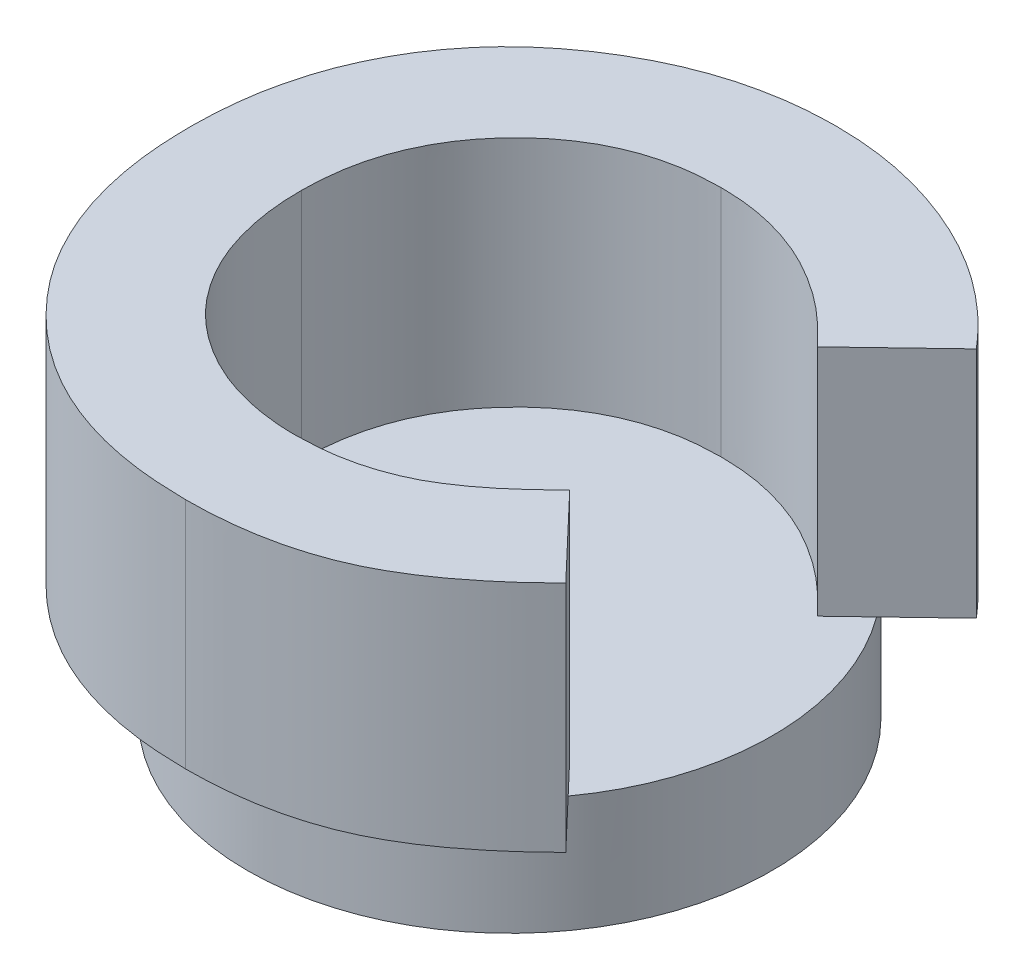
from build123d import *

# Parameters (mm, degrees)
SKETCH1_R           = 22.5
BOSS_EXTRUDE1_DEPTH = 10
BOSS_EXTRUDE2_DEPTH = 20
SKETCH3_R           = 16.5
CUT_EXTRUDE2_DEPTH  = 5


with BuildPart() as part:
    # Sketch1 → Boss-Extrude1 (new body)
    with BuildSketch(Plane(origin=(0, 0, 0), x_dir=(1, 0, 0), z_dir=(0, 1, 0))):
        with Locations(Location((0, 0, 0), (0, 0, 270))):
            Circle(SKETCH1_R)
    extrude(amount=BOSS_EXTRUDE1_DEPTH)

    # Sketch2 → Boss-Extrude2 (add)
    with BuildSketch(Plane(origin=(0, 10, 0), x_dir=(1, 0, 0), z_dir=(0, 1, 0))):
        with BuildLine():
            Line((22.514356491, 17.490690637), (15.549963462, 10.833706128))
            add(Edge.make_bspline(
                [(15.549963462, 10.833706128), (14.959186907, 11.444570075), (13.805215213, 12.637778742), (11.945732542, 14.217481862), (10.01193827, 15.533950672), (8.041450503, 16.642672321), (5.998825878, 17.481499268), (3.907682699, 18.092766593), (1.754668401, 18.465433177), (0.297591136, 18.508072829), (-0.435279594, 18.529519429)],
                knots=[0, 0, 0, 0, 1.115251505, 2.178435587, 3.19620269, 4.182487026, 5.141301733, 6.088180966, 7.038406374, 8, 8, 8, 8], degree=3))
            add(Edge.make_bspline(
                [(-0.435279594, 18.529519429), (-1.047315714, 18.512575866), (-2.255101565, 18.47913961), (-4.028447695, 18.234018873), (-5.724744916, 17.817180392), (-7.349799924, 17.242699751), (-8.898830923, 16.499352293), (-10.37508565, 15.587713348), (-11.77492446, 14.516016314), (-13.079856293, 13.2898062), (-14.273562073, 11.950079505), (-15.328277138, 10.520594316), (-16.211770191, 9.004625506), (-16.936838569, 7.417525692), (-17.501638807, 5.75194899), (-17.904977137, 4.009016732), (-18.138257248, 2.186653221), (-18.173075868, 0.947824086), (-18.190771715, 0.318214675)],
                knots=[0, 0, 0, 0, 1.035432265, 2.043311493, 3.022114605, 3.98653278, 4.95457646, 5.923598177, 6.917315552, 7.932509744, 8.948865224, 9.949768934, 10.933144597, 11.912367597, 12.897413939, 13.903909035, 14.934704909, 16, 16, 16, 16], degree=3))
            add(Edge.make_bspline(
                [(-18.190771715, 0.318214675), (-18.185671973, -0.123689261), (-18.175620278, -0.994691), (-18.065586703, -2.283144309), (-17.888406699, -3.533248623), (-17.631983338, -4.743110368), (-17.311323403, -5.91377802), (-16.935116286, -7.055350871), (-16.463169991, -8.152054953), (-15.939302484, -9.216627772), (-15.330050609, -10.220021127), (-14.673164696, -11.176839965), (-13.960879171, -12.082394056), (-13.188580519, -12.932981467), (-12.345399597, -13.715309421), (-11.453129512, -14.452903451), (-10.496718903, -15.127299081), (-9.496034842, -15.75542101), (-8.442432682, -16.301075874), (-7.364499094, -16.795333764), (-6.245890431, -17.196744657), (-5.100226426, -17.520318456), (-3.931601279, -17.795469647), (-2.72858475, -17.964888691), (-1.501605485, -18.09318775), (-0.67237345, -18.101109467), (-0.255074599, -18.105095955)],
                knots=[0, 0, 0, 0, 1.103660481, 2.175337485, 3.227646561, 4.255952547, 5.262355991, 6.258840057, 7.255597736, 8.242457506, 9.22035537, 10.185017736, 11.140346927, 12.096287581, 13.051739095, 14.01125915, 14.986044842, 15.97314143, 16.960198552, 17.947847494, 18.933482797, 19.925264591, 20.920966487, 21.929612487, 22.958107872, 24, 24, 24, 24], degree=3))
            add(Edge.make_bspline(
                [(-0.255074599, -18.105095955), (0.452735966, -18.084622318), (1.843399669, -18.044396943), (3.884398613, -17.729840213), (5.829267273, -17.212412193), (7.383208025, -16.601359767), (8.600679559, -15.997937564), (9.52752264, -15.439801741), (10.485950624, -14.815465543), (11.460044841, -14.101365846), (12.460761919, -13.306072133), (13.470436894, -12.412165987), (14.514917625, -11.449082455), (15.199146599, -10.761710818), (15.549963462, -10.409282654)],
                knots=[0, 0, 0, 0, 1.404581149, 2.759636711, 4.088442092, 5.392261763, 6.066678138, 6.783632037, 7.538459478, 8.336747902, 9.180226004, 10.074962426, 11.012997595, 12, 12, 12, 12], degree=3))
            Line((15.549963462, -10.409282654), (22.302350615, -17.500879208))
            add(Edge.make_bspline(
                [(22.302350615, -17.500879208), (21.827694143, -17.95914513), (20.901266219, -18.853582206), (19.503775414, -20.12359939), (18.108043407, -21.264851013), (16.747788174, -22.318759505), (15.400727318, -23.254621954), (14.067003691, -24.073373015), (12.761715627, -24.795720088), (11.457758402, -25.409481144), (10.147018122, -25.930628026), (8.798420406, -26.379301284), (7.407842465, -26.75886272), (5.966791283, -27.06511895), (4.488708107, -27.310695102), (2.959760044, -27.476457584), (1.389641377, -27.587894186), (0.324605561, -27.597907688), (-0.212673424, -27.602959203)],
                knots=[0, 0, 0, 0, 1.244526981, 2.429050516, 3.560637417, 4.644440555, 5.67424972, 6.652764056, 7.595344123, 8.486817594, 9.369275933, 10.254498637, 11.166417451, 12.086725134, 13.032340136, 13.991389299, 14.986715468, 16, 16, 16, 16], degree=3))
            add(Edge.make_bspline(
                [(-0.212673424, -27.602959203), (-1.199588367, -27.577800773), (-3.130706581, -27.528572719), (-5.960709972, -27.163826165), (-8.649137226, -26.552334995), (-11.202528785, -25.687517816), (-13.620072728, -24.582754401), (-15.901150575, -23.22836633), (-18.042085734, -21.627951998), (-20.025583664, -19.800269815), (-21.819751941, -17.781748276), (-23.405588922, -15.614409906), (-24.717393333, -13.287603029), (-25.806612801, -10.835702017), (-26.658368101, -8.247517893), (-27.257859435, -5.520251029), (-27.627561366, -2.656534771), (-27.668007283, -0.700550553), (-27.688634962, 0.297014088)],
                knots=[0, 0, 0, 0, 1.078019885, 2.10938526, 3.111377082, 4.085535484, 5.04941344, 6.010039228, 6.978205633, 7.964457913, 8.951525778, 9.924444315, 10.892603023, 11.863865945, 12.85144698, 13.863884204, 14.910567087, 16, 16, 16, 16], degree=3))
            add(Edge.make_bspline(
                [(-27.688634962, 0.297014088), (-27.679918705, 0.947617235), (-27.662645212, 2.23695366), (-27.481099205, 4.136250673), (-27.228013516, 5.987725528), (-26.826516082, 7.772153781), (-26.342550525, 9.513574972), (-25.74067577, 11.193061886), (-25.021853092, 12.815441538), (-24.20925184, 14.383429889), (-23.289964174, 15.886754934), (-22.263018932, 17.312500744), (-21.154853689, 18.671673812), (-19.93884104, 19.946242185), (-18.632651242, 21.14739682), (-17.230386997, 22.268628432), (-15.740482224, 23.326016746), (-14.158904306, 24.292294284), (-12.516379087, 25.166343676), (-10.833623133, 25.937292571), (-9.114770779, 26.581628309), (-7.367089489, 27.116081037), (-5.583195332, 27.515012207), (-3.775821291, 27.816990234), (-1.929588783, 27.985797881), (-0.690003597, 28.013432771), (-0.064269311, 28.027382677)],
                knots=[0, 0, 0, 0, 1.071919942, 2.124283339, 3.142214191, 4.149696895, 5.136002878, 6.119640489, 7.086990633, 8.058538607, 9.028339693, 9.988281803, 10.952401235, 11.916291999, 12.888973767, 13.874849856, 14.873389453, 15.898127285, 16.927174885, 17.938320013, 18.946391617, 19.950418109, 20.947802303, 21.956882652, 22.968648068, 24, 24, 24, 24], degree=3))
            add(Edge.make_bspline(
                [(-0.064269311, 28.027382677), (0.469546195, 28.019386243), (1.53162701, 28.003476514), (3.113243568, 27.870851616), (4.682211098, 27.662565556), (6.232912213, 27.348306247), (7.776439114, 26.975240735), (9.292508128, 26.486762906), (10.805036063, 25.942262312), (12.290301164, 25.291423032), (13.750376645, 24.580973168), (15.151057936, 23.774941998), (16.515862348, 22.922931778), (17.814546634, 21.974516811), (19.071437948, 20.964097872), (20.279963894, 19.886960788), (21.429518951, 18.725146522), (22.150915876, 17.904256161), (22.514356491, 17.490690637)],
                knots=[0, 0, 0, 0, 0.996412454, 1.982464992, 2.961075852, 3.949442424, 4.934965278, 5.923860011, 6.921385422, 7.934793307, 8.949617135, 9.951082467, 10.950285876, 11.951772932, 12.951063433, 13.960125323, 14.972308753, 16, 16, 16, 16], degree=3))
        make_face()
    extrude(amount=BOSS_EXTRUDE2_DEPTH)

    # Sketch3 → Cut-Extrude2 (cut)
    with BuildSketch(Plane.XZ):
        with BuildLine():
            ThreePointArc((-14.551420086, 2.778571429), (0, 11.5), (14.551420086, 2.778571429))
            Line((14.551420086, 2.778571429), (4.83856504, 20.948467447))
            ThreePointArc((4.83856504, 20.948467447), (0, 21.5), (-4.83856504, 20.948467447))
            Line((-4.83856504, 20.948467447), (-14.551420086, 2.778571429))
        make_face()
        with Locations((0, -5)):
            Circle(SKETCH3_R)
    extrude(amount=-CUT_EXTRUDE2_DEPTH, mode=Mode.SUBTRACT)


solid = part.part
